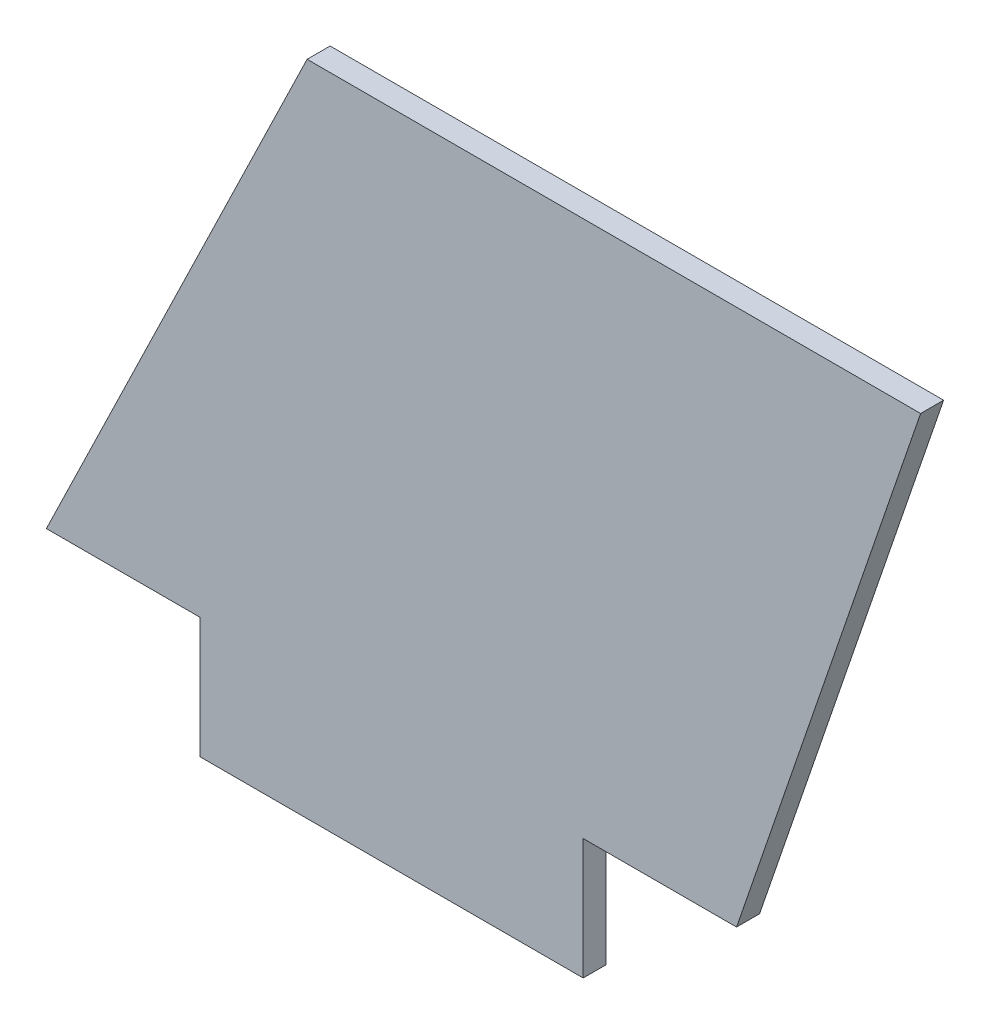
from build123d import *

# Parameters (mm, degrees)
BOSS_EXTRUDE1_DEPTH = 1.5


with BuildPart() as part:
    # Sketch1 → Boss-Extrude1 (new body)
    with BuildSketch(Plane.XY):
        Polygon((0, 0), (10, 0), (10, -7.875), (35, -7.875), (35, 0), (45, 0), (57, 35), (17, 35), align=None)
    extrude(amount=BOSS_EXTRUDE1_DEPTH)


solid = part.part
